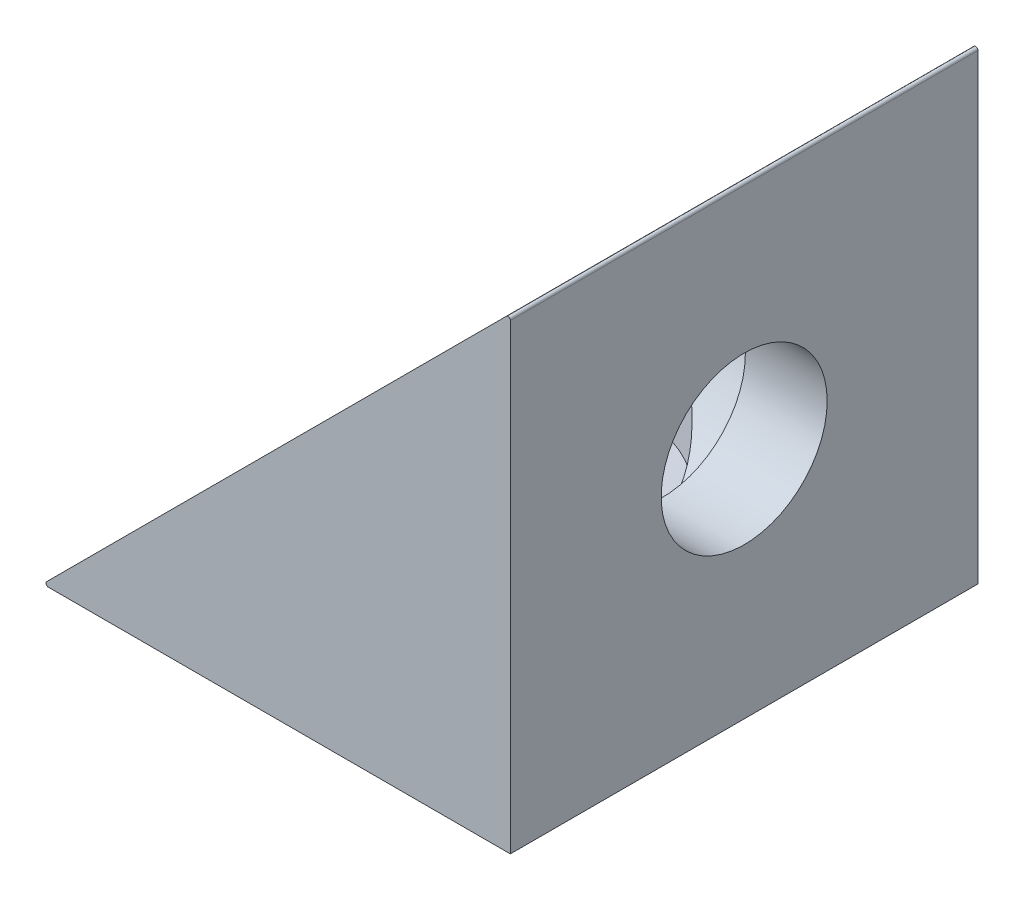
from build123d import *

# Parameters (mm, degrees)
BOSS_EXTRU_1_DEPTH      = 20
ESQUISSE2_R             = 3.55
ENL_V_MAT_EXTRU_1_DEPTH = 21
ESQUISSE3_R             = 3.55
ENL_V_MAT_EXTRU_2_DEPTH = 21
ENL_V_START             = -3.5
ESQUISSE4_R             = 5.5
ENL_V_MAT_EXTRU_3_DEPTH = 17.5
ESQUISSE5_R             = 5.5
ENL_V_MAT_EXTRU_4_DEPTH = 17.5
CONG_1_R                = 0.1


with BuildPart() as part:
    # Esquisse1 → Boss.-Extru.1 (new body)
    with BuildSketch(Plane.XY):
        Polygon((-20, -20), (0, 0), (0, -20), align=None)
    extrude(amount=BOSS_EXTRU_1_DEPTH)

    # Esquisse2 → Enlèv. mat.-Extru.1 (cut, through all)
    with BuildSketch(Plane.XZ.offset(20)):
        with Locations((-10, 10)):
            Circle(ESQUISSE2_R)
    extrude(amount=-ENL_V_MAT_EXTRU_1_DEPTH, mode=Mode.SUBTRACT)

    # Esquisse3 → Enlèv. mat.-Extru.2 (cut, through all)
    with BuildSketch(Plane(origin=(0, 0, 0), x_dir=(0, 0, 1), z_dir=(1, 0, 0))):
        with Locations((10, 10)):
            Circle(ESQUISSE3_R)
    extrude(amount=-ENL_V_MAT_EXTRU_2_DEPTH, mode=Mode.SUBTRACT)

    # Esquisse4 → Enlèv. mat.-Extru.3 (cut, through all)
    with BuildSketch(Plane(origin=(0, 0, 0), x_dir=(0, 0, -1), z_dir=(1, 0, 0)).offset(ENL_V_START)):
        with Locations((-10, -10)):
            Circle(ESQUISSE4_R)
    extrude(amount=-ENL_V_MAT_EXTRU_3_DEPTH, mode=Mode.SUBTRACT)

    # Esquisse5 → Enlèv. mat.-Extru.4 (cut, through all)
    with BuildSketch(Plane.XZ.offset(20).offset(ENL_V_START)):
        with Locations((-10, 10)):
            Circle(ESQUISSE5_R)
    extrude(amount=-ENL_V_MAT_EXTRU_4_DEPTH, mode=Mode.SUBTRACT)

    # Congé1
    cong_1_edges = [part.edges().sort_by_distance(p)[0] for p in [
        (-20, -20, 10),
        (0, 0, 10),
    ]]
    fillet(cong_1_edges, radius=CONG_1_R)


solid = part.part
